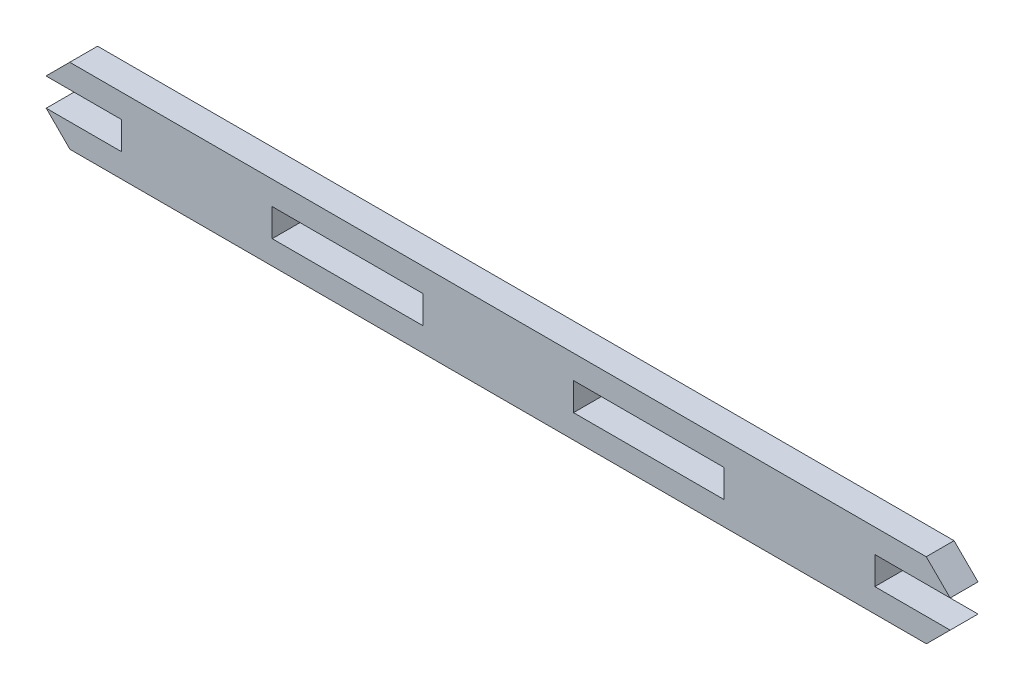
from build123d import *

# Parameters (mm, degrees)
SKETCH2_W           = 30
SKETCH2_H           = 5.54
BOSS_EXTRUDE1_DEPTH = 5.54


with BuildPart() as part:
    # Sketch2 → Boss-Extrude1 (new body)
    with BuildSketch(Plane.XY):
        Polygon((55.611665542, 15.146039761), (226.151665542, 15.146039761), (230.922330423, 10.416039761), (215.922330423, 10.416039761), (215.922330423, 4.876039761), (230.922330423, 4.876039761), (226.190313127, 0.146039761), (55.650313127, 0.146039761), (50.922330423, 4.876039761), (65.922330423, 4.876039761), (65.922330423, 10.415990403), (50.881665543, 10.415990403), align=None)
        with Locations((170.922330423, 7.646039761)):
            Rectangle(SKETCH2_W, SKETCH2_H, mode=Mode.SUBTRACT)
        with Locations((110.922330423, 7.646039761)):
            Rectangle(SKETCH2_W, SKETCH2_H, mode=Mode.SUBTRACT)
    extrude(amount=BOSS_EXTRUDE1_DEPTH)


solid = part.part
